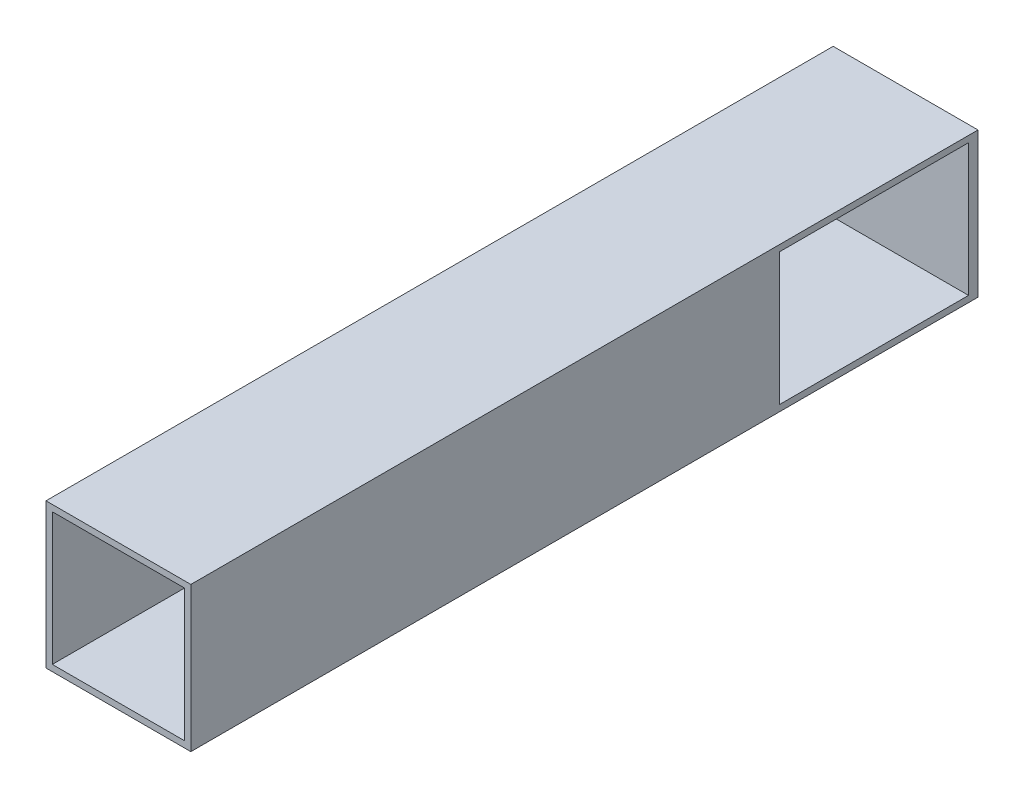
from build123d import *

# Parameters (mm, degrees)
SKETCH2_W           = 116.84
SKETCH2_H           = 116.84
BOSS_EXTRUDE1_DEPTH = 635
SKETCH3_W           = 106.68
SKETCH3_H           = 106.68
CUT_EXTRUDE1_DEPTH  = 627.38
SKETCH4_W           = 152.4
SKETCH4_H           = 106.68
CUT_EXTRUDE2_DEPTH  = 7.62


with BuildPart() as part:
    # Sketch2 → Boss-Extrude1 (new body)
    with BuildSketch(Plane.XY):
        with Locations((72.050995802, -43.130189795)):
            Rectangle(SKETCH2_W, SKETCH2_H)
    extrude(amount=BOSS_EXTRUDE1_DEPTH)

    # Sketch3 → Cut-Extrude1 (cut)
    with BuildSketch(Plane.XY.offset(635)):
        with Locations((72.050995802, -43.130189795)):
            Rectangle(SKETCH3_W, SKETCH3_H)
    extrude(amount=-CUT_EXTRUDE1_DEPTH, mode=Mode.SUBTRACT)

    # Sketch4 → Cut-Extrude2 (cut)
    with BuildSketch(Plane(origin=(130.470995802, 0, 0), x_dir=(0, 0, -1), z_dir=(1, 0, 0))):
        with Locations((-83.82, -43.130189795)):
            Rectangle(SKETCH4_W, SKETCH4_H)
    extrude(amount=-CUT_EXTRUDE2_DEPTH, mode=Mode.SUBTRACT)


solid = part.part
